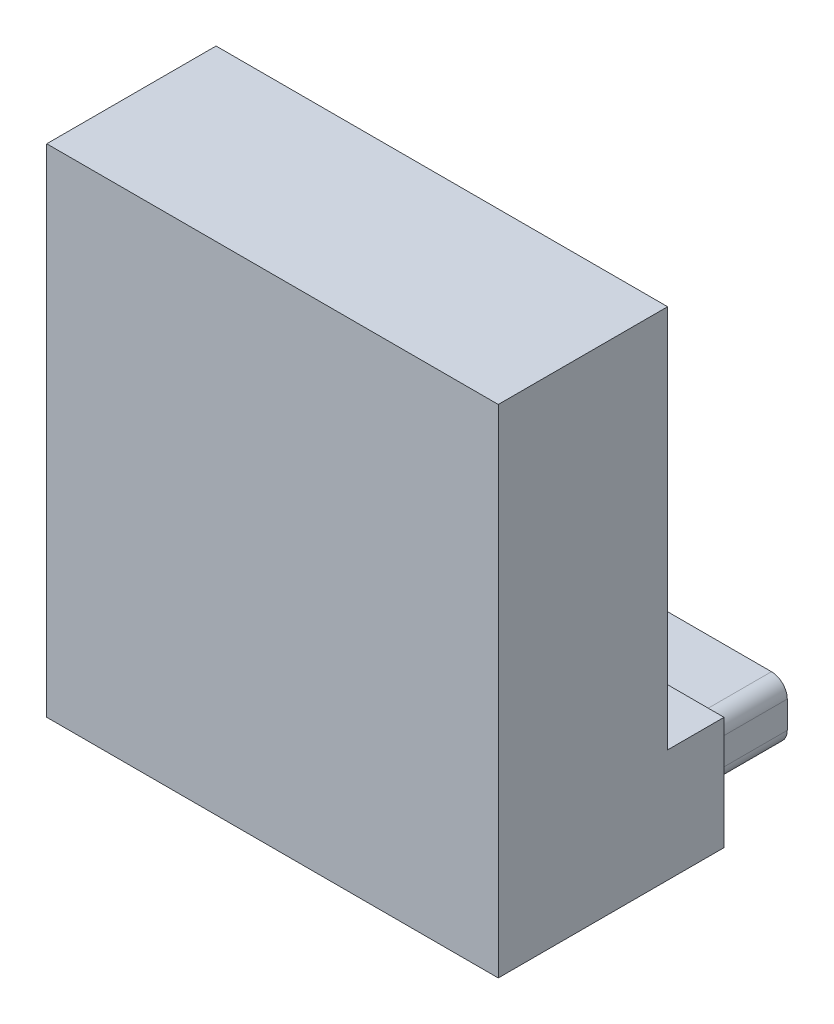
from build123d import *

# Parameters (mm, degrees)
SKETCH1_W           = 20
SKETCH1_H           = 10
BOSS_EXTRUDE1_DEPTH = 5
SKETCH2_W           = 17.6
SKETCH2_H           = 2.6
BOSS_EXTRUDE2_DEPTH = 4
FILLET1_R           = 0.7
SKETCH3_W           = 20
SKETCH3_H           = 7.5
BOSS_EXTRUDE3_DEPTH = 17
SKETCH4_R           = 2.1
BOSS_EXTRUDE4_DEPTH = 6.5


with BuildPart() as part:
    # Sketch1 → Boss-Extrude1 (new body)
    with BuildSketch(Plane(origin=(0, 0, 0), x_dir=(1, 0, 0), z_dir=(0, 1, 0))):
        Rectangle(SKETCH1_W, SKETCH1_H)
    extrude(amount=BOSS_EXTRUDE1_DEPTH)

    # Sketch2 → Boss-Extrude2 (add)
    with BuildSketch(Plane(origin=(0, 0, -5), x_dir=(-1, 0, 0), z_dir=(0, 0, -1))):
        with Locations((0, 2.5)):
            Rectangle(SKETCH2_W, SKETCH2_H)
    extrude(amount=BOSS_EXTRUDE2_DEPTH)

    # Fillet1
    fillet1_edges = [part.edges().sort_by_distance(p)[0] for p in [
        (-8.8, 1.2, -7),
        (-8.8, 3.8, -7),
        (8.8, 3.8, -7),
        (8.8, 1.2, -7),
    ]]
    fillet(fillet1_edges, radius=FILLET1_R)

    # Sketch3 → Boss-Extrude3 (add)
    with BuildSketch(Plane(origin=(0, 5, 0), x_dir=(1, 0, 0), z_dir=(0, 1, 0))):
        with Locations((0, -1.25)):
            Rectangle(SKETCH3_W, SKETCH3_H)
    extrude(amount=BOSS_EXTRUDE3_DEPTH)

    # Sketch4 → Boss-Extrude4 (add)
    with BuildSketch(Plane(origin=(0, 0, -2.5), x_dir=(-1, 0, 0), z_dir=(0, 0, -1))):
        with Locations((0, 12)):
            Circle(SKETCH4_R)
    extrude(amount=BOSS_EXTRUDE4_DEPTH)


solid = part.part
